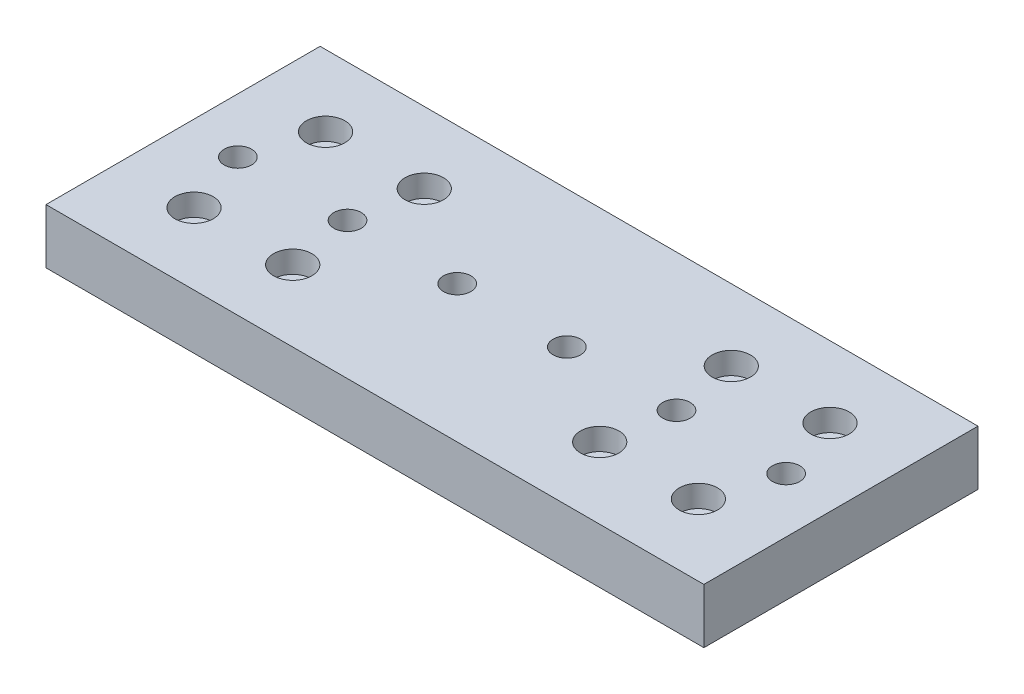
from build123d import *

# Parameters (mm, degrees)
SKETCH1_W                        = 120
SKETCH1_H                        = 50
MAIN_DEPTH                       = 10
SKETCH2_R                        = 1.5
LINEAR_BEARING_MOUNT_DEPTH       = 11
SKETCH5_R                        = 3.5
LINEAR_BEARING_COUNTERSINK_DEPTH = 4
SKETCH6_R                        = 2.5
CUT_EXTRUDE1_DEPTH               = 11
SKETCH7_R                        = 4.3
CUT_EXTRUDE2_DEPTH               = 5


with BuildPart() as part:
    # Sketch1 → main (new body)
    with BuildSketch(Plane(origin=(0, 0, 0), x_dir=(1, 0, 0), z_dir=(0, 1, 0))):
        Rectangle(SKETCH1_W, SKETCH1_H)
    extrude(amount=MAIN_DEPTH)

    # Sketch2 → linear_bearing_mount (cut, through all)
    with BuildSketch(Plane(origin=(0, 10, 0), x_dir=(1, 0, 0), z_dir=(0, 1, 0))):
        with Locations((-28, -12)):
            Circle(SKETCH2_R)
        with Locations((-46, -12)):
            Circle(SKETCH2_R)
        with Locations((28, -12)):
            Circle(SKETCH2_R)
        with Locations((46, -12)):
            Circle(SKETCH2_R)
        with Locations((46, 12)):
            Circle(SKETCH2_R)
        with Locations((28, 12)):
            Circle(SKETCH2_R)
        with Locations((-46, 12)):
            Circle(SKETCH2_R)
        with Locations((-28, 12)):
            Circle(SKETCH2_R)
    extrude(amount=-LINEAR_BEARING_MOUNT_DEPTH, mode=Mode.SUBTRACT)

    # Sketch5 → linear_bearing_countersink (cut)
    with BuildSketch(Plane(origin=(0, 10, 0), x_dir=(1, 0, 0), z_dir=(0, 1, 0))):
        with Locations((-46, 12)):
            Circle(SKETCH5_R)
        with Locations((-28, 12)):
            Circle(SKETCH5_R)
        with Locations((-28, -12)):
            Circle(SKETCH5_R)
        with Locations((-46, -12)):
            Circle(SKETCH5_R)
        with Locations((46, -12)):
            Circle(SKETCH5_R)
        with Locations((28, -12)):
            Circle(SKETCH5_R)
        with Locations((28, 12)):
            Circle(SKETCH5_R)
        with Locations((46, 12)):
            Circle(SKETCH5_R)
    extrude(amount=-LINEAR_BEARING_COUNTERSINK_DEPTH, mode=Mode.SUBTRACT)

    # Sketch6 → Cut-Extrude1 (cut, through all)
    with BuildSketch(Plane.XZ):
        with Locations((-50, 0)):
            Circle(SKETCH6_R)
        with Locations((-30, 0)):
            Circle(SKETCH6_R)
        with Locations((-10, 0)):
            Circle(SKETCH6_R)
        with Locations((10, 0)):
            Circle(SKETCH6_R)
        with Locations((30, 0)):
            Circle(SKETCH6_R)
        with Locations((50, 0)):
            Circle(SKETCH6_R)
    extrude(amount=-CUT_EXTRUDE1_DEPTH, mode=Mode.SUBTRACT)

    # Sketch7 → Cut-Extrude2 (cut)
    with BuildSketch(Plane.XZ):
        with Locations((-50, 0)):
            Circle(SKETCH7_R)
        with Locations((-30, 0)):
            Circle(SKETCH7_R)
        with Locations((-10, 0)):
            Circle(SKETCH7_R)
        with Locations((10, 0)):
            Circle(SKETCH7_R)
        with Locations((30, 0)):
            Circle(SKETCH7_R)
        with Locations((50, 0)):
            Circle(SKETCH7_R)
    extrude(amount=-CUT_EXTRUDE2_DEPTH, mode=Mode.SUBTRACT)


solid = part.part
